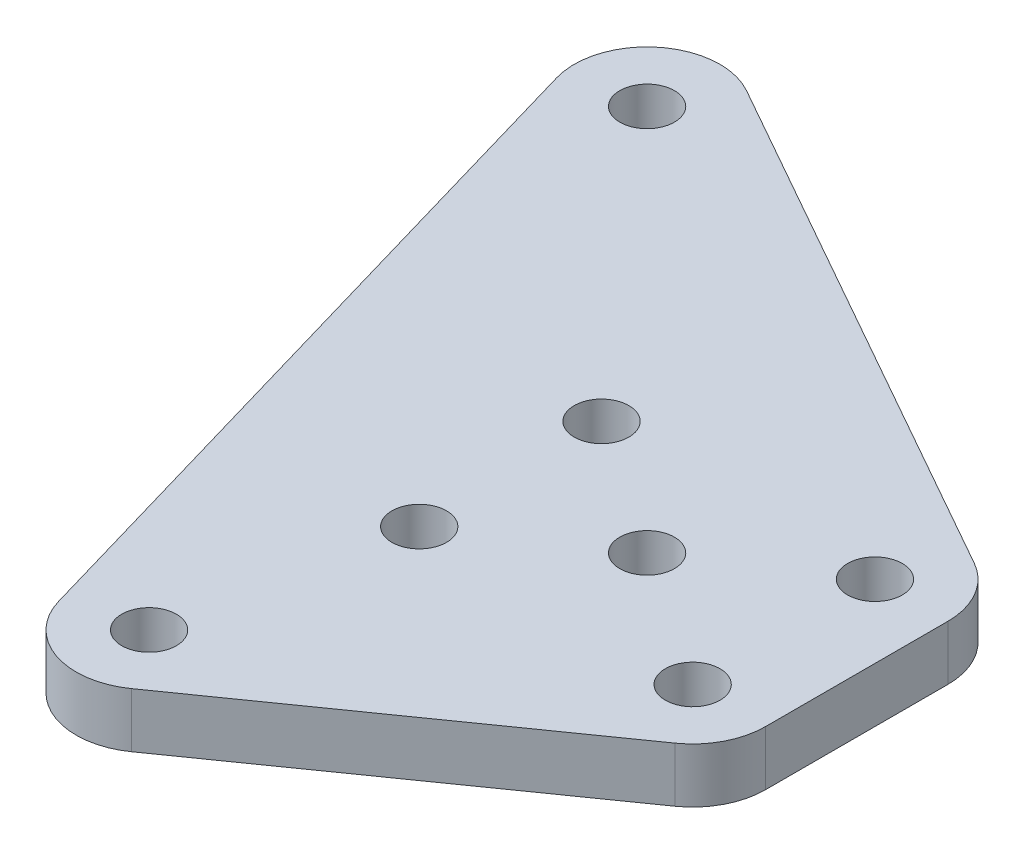
from build123d import *

# Parameters (mm, degrees)
SKETCH1_R           = 1.5
BOSS_EXTRUDE1_DEPTH = 3


with BuildPart() as part:
    # Sketch1 → Boss-Extrude1 (new body)
    with BuildSketch(Plane(origin=(0, 0, 0), x_dir=(1, 0, 0), z_dir=(0, 1, 0))):
        with BuildLine():
            Line((-0.840713059, -22.537580563), (16.659286941, -10.217072487))
            ThreePointArc((16.659286941, -10.217072487), (17.907005983, -8.788799729), (18.356601718, -6.94634768))
            Line((18.356601718, -6.94634768), (18.356601718, 3.05365232))
            ThreePointArc((18.356601718, 3.05365232), (17.811093873, 5.070204812), (16.323359741, 6.536734702))
            Line((16.323359741, 6.536734702), (-12.389843694, 22.749938137))
            ThreePointArc((-12.389843694, 22.749938137), (-16.840458568, 22.402211421), (-18.197292095, 18.149225482))
            Line((-18.197292095, 18.149225482), (-6.984088659, -20.384486029))
            ThreePointArc((-6.984088659, -20.384486029), (-4.466394496, -23.041730723), (-0.840713059, -22.537580563))
        make_face()
        with Locations((14.356601718, -6.94634768)):
            Circle(SKETCH1_R, mode=Mode.SUBTRACT)
        with Locations((14.356601718, 3.05365232)):
            Circle(SKETCH1_R, mode=Mode.SUBTRACT)
        with Locations((6.856601718, -1.94634768)):
            Circle(SKETCH1_R, mode=Mode.SUBTRACT)
        with Locations((-3.143398282, -19.266855756)):
            Circle(SKETCH1_R, mode=Mode.SUBTRACT)
        with Locations((-0.643398282, -6.94634768)):
            Circle(SKETCH1_R, mode=Mode.SUBTRACT)
        with Locations((-0.643398282, 3.05365232)):
            Circle(SKETCH1_R, mode=Mode.SUBTRACT)
        with Locations((-14.356601718, 19.266855756)):
            Circle(SKETCH1_R, mode=Mode.SUBTRACT)
    extrude(amount=BOSS_EXTRUDE1_DEPTH)


solid = part.part
